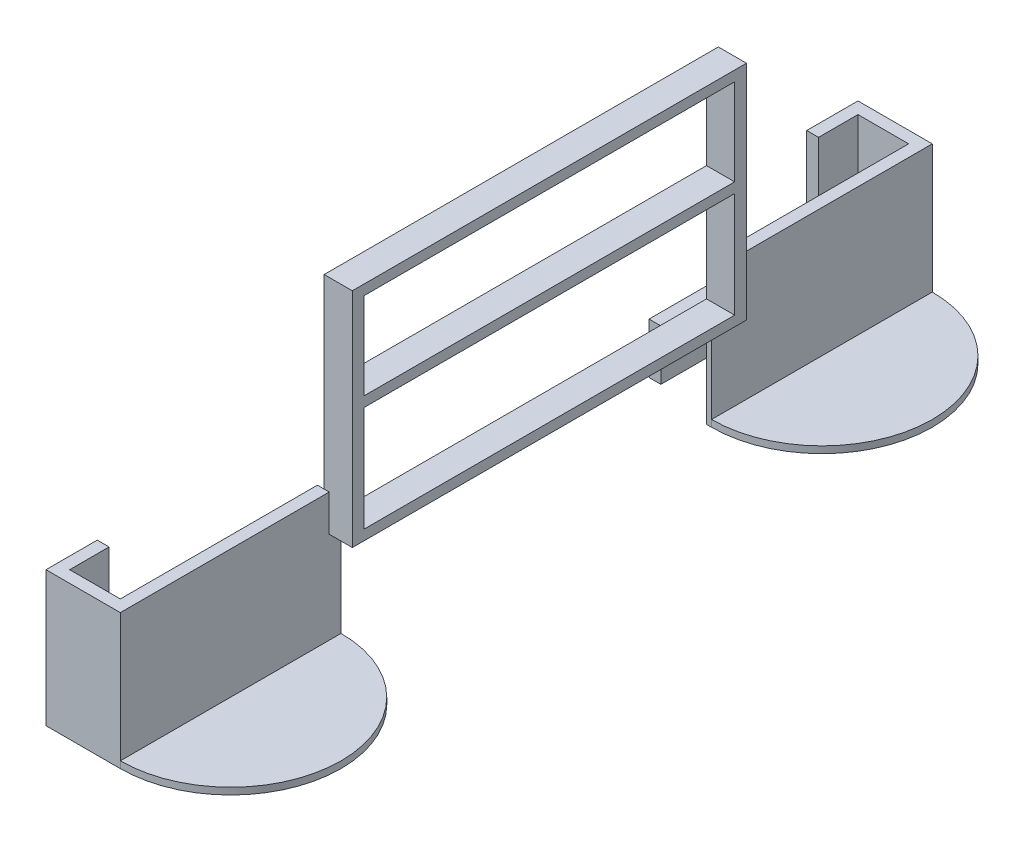
from build123d import *

# Parameters (mm, degrees)
SALIENTE_EXTRUIR2_DEPTH  = 35
CROQUIS4_W               = 9
CROQUIS4_H               = 15
CORTAR_EXTRUIR1_DEPTH    = 70
SALIENTE_EXTRUIR3_DEPTH  = 2.1
CROQUIS8_W               = 2.1
CROQUIS8_H               = 15
SALIENTE_EXTRUIR4_DEPTH  = 7
SALIENTE_EXTRUIR5_START  = -2.1
CROQUIS9_W               = 28
CROQUIS9_H               = 15
SALIENTE_EXTRUIR5_DEPTH  = 2.1
SALIENTE_EXTRUIR6_START  = -2.1
CROQUIS10_W              = 9
CROQUIS10_H              = 15
SALIENTE_EXTRUIR6_DEPTH  = 2.1
SALIENTE_EXTRUIR7_DEPTH  = 0.9
SALIENTE_EXTRUIR8_DEPTH  = 1.2
CROQUIS16_W              = 70
CROQUIS16_H              = 39.5
CROQUIS16_W_2            = 65.8
CROQUIS16_H_2            = 15.4
CROQUIS16_H_3            = 18.7
SALIENTE_EXTRUIR10_DEPTH = 4.1


with BuildPart() as part:
    # Croquis3 → Saliente-Extruir2 (new body)
    with BuildSketch(Plane.XY):
        Polygon((-207.232131222, -11.93013618), (-207.232131222, -18.93013618), (-207.232131222, -20.93013618), (-194.032131222, -20.93013618), (-194.032131222, -11.93013618), (-196.132131222, -11.93013618), (-196.132131222, -18.93013618), (-205.132131222, -18.93013618), (-205.132131222, -11.93013618), align=None)
    extrude(amount=SALIENTE_EXTRUIR2_DEPTH)

    # Croquis4 → Cortar-Extruir1 (cut)
    with BuildSketch(Plane(origin=(0, -18.93013618, 0), x_dir=(1, 0, 0), z_dir=(0, 1, 0))):
        with Locations((-200.632131222, -7.5)):
            Rectangle(CROQUIS4_W, CROQUIS4_H)
    extrude(amount=-CORTAR_EXTRUIR1_DEPTH, mode=Mode.SUBTRACT)

    # Croquis7 → Saliente-Extruir3 (add)
    with BuildSketch(Plane.XY.offset(35)):
        Polygon((-205.132131222, -11.93013618), (-205.132131222, 3.06986382), (-207.232131222, 3.06986382), (-207.232131222, -20.93013618), (-194.032131222, -20.93013618), (-194.032131222, 3.06986382), (-196.132131222, 3.06986382), (-196.132131222, -11.93013618), align=None)
    extrude(amount=SALIENTE_EXTRUIR3_DEPTH)

    # Croquis8 → Saliente-Extruir4 (add)
    with BuildSketch(Plane(origin=(0, 0, 35), x_dir=(-1, 0, 0), z_dir=(0, 0, -1))):
        with Locations((195.082131222, -4.43013618)):
            Rectangle(CROQUIS8_W, CROQUIS8_H)
        with Locations((206.182131222, -4.43013618)):
            Rectangle(CROQUIS8_W, CROQUIS8_H)
    extrude(amount=SALIENTE_EXTRUIR4_DEPTH)

    # Croquis9 → Saliente-Extruir5 (add)
    with BuildSketch(Plane(origin=(-194.032131222, 0, 0), x_dir=(0, 0, -1), z_dir=(1, 0, 0)).offset(SALIENTE_EXTRUIR5_START)):
        with Locations((-14, -4.43013618)):
            Rectangle(CROQUIS9_W, CROQUIS9_H)
    extrude(amount=SALIENTE_EXTRUIR5_DEPTH)

    # Croquis10 → Saliente-Extruir6 (add)
    with BuildSketch(Plane.XY.offset(37.1).offset(SALIENTE_EXTRUIR6_START)):
        with Locations((-200.632131222, -4.43013618)):
            Rectangle(CROQUIS10_W, CROQUIS10_H)
    extrude(amount=SALIENTE_EXTRUIR6_DEPTH)

    # Croquis12 → Saliente-Extruir7 (add)
    with BuildSketch(Plane(origin=(-194.032131222, 0, 0), x_dir=(0, 0, -1), z_dir=(1, 0, 0))):
        Polygon((0, 3.06986382), (0, 36.06986382), (35, 36.06986382), (35, 34.26986382), (2.1, 34.26986382), (2.1, 18.86986382), (35, 18.86986382), (35, 17.06986382), (2.1, 17.06986382), (2.1, -1.63013618), (35, -1.63013618), (35, -3.43013618), (2.1, -3.43013618), (2.1, -20.93013618), (0, -20.93013618), align=None)
    extrude(amount=-SALIENTE_EXTRUIR7_DEPTH)

    # Simetría5: part across plane


with BuildPart() as part_1:
    add(part.part)
    add(part.part.mirror(Plane(origin=(0, 0, -35), x_dir=(1, 0, 0), z_dir=(0, 0, -1))))

    # Croquis13 → Saliente-Extruir8 (add)
    with BuildSketch(Plane.XZ.offset(20.93013618)):
        with BuildLine():
            Line((-194.032131222, 37.1), (-194.032131222, -2.1))
            ThreePointArc((-194.032131222, -2.1), (-174.432131222, 17.5), (-194.032131222, 37.1))
        make_face()
        with BuildLine():
            Line((-194.032131222, -67.9), (-194.032131222, -107.1))
            ThreePointArc((-194.032131222, -107.1), (-174.432131222, -87.5), (-194.032131222, -67.9))
        make_face()
    extrude(amount=-SALIENTE_EXTRUIR8_DEPTH)

    # Croquis16 → Saliente-Extruir10 (add)
    with BuildSketch(Plane(origin=(-194.032131222, 0, 0), x_dir=(0, 0, -1), z_dir=(1, 0, 0))):
        with Locations((35, 16.31986382)):
            Rectangle(CROQUIS16_W, CROQUIS16_H)
        with Locations((35, 26.56986382)):
            Rectangle(CROQUIS16_W_2, CROQUIS16_H_2, mode=Mode.SUBTRACT)
        with Locations((35, 7.71986382)):
            Rectangle(CROQUIS16_W_2, CROQUIS16_H_3, mode=Mode.SUBTRACT)
    extrude(amount=SALIENTE_EXTRUIR10_DEPTH)


solid = part_1.part
